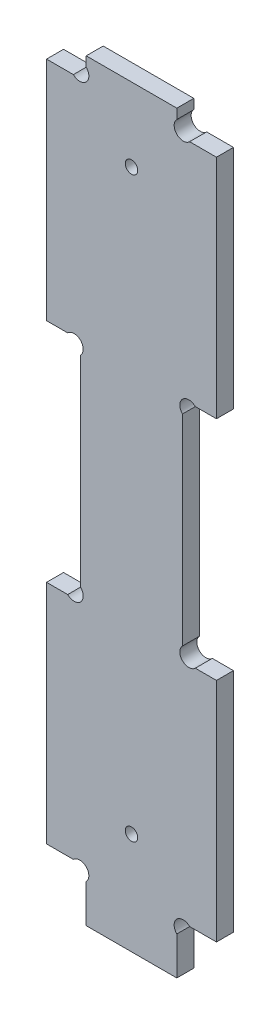
from build123d import *

# Parameters (mm, degrees)
EXTRUSION1_DEPTH        = 3
ESQUISSE2_R             = 1.1
ENL_V_MAT_EXTRU_1_DEPTH = 4


with BuildPart() as part:
    # Esquisse1 → Extrusion1 (new body)
    with BuildSketch(Plane.XY):
        with BuildLine():
            Line((25.2627417, 9), (30, 9))
            Line((30, 9), (30, 49))
            Line((30, 49), (26.2627417, 49))
            ThreePointArc((26.2627417, 49), (24, 49), (24, 51.2627417))
            Line((24, 51.2627417), (24, 86.7372583))
            ThreePointArc((24, 86.7372583), (24, 89), (26.2627417, 89))
            Line((26.2627417, 89), (30, 89))
            Line((30, 89), (30, 129))
            Line((30, 129), (25.2627417, 129))
            ThreePointArc((25.2627417, 129), (23, 129), (23, 131.2627417))
            Line((23, 131.2627417), (23, 133))
            Line((23, 133), (7, 133))
            Line((7, 133), (7, 131.2627417))
            ThreePointArc((7, 131.2627417), (7, 129), (4.7372583, 129))
            Line((4.7372583, 129), (0, 129))
            Line((0, 129), (0, 89))
            Line((0, 89), (3.7372583, 89))
            ThreePointArc((3.7372583, 89), (6, 89), (6, 86.7372583))
            Line((6, 86.7372583), (6, 51.2627417))
            ThreePointArc((6, 51.2627417), (6, 49), (3.7372583, 49))
            Line((3.7372583, 49), (0, 49))
            Line((0, 49), (0, 9))
            Line((0, 9), (4.7372583, 9))
            ThreePointArc((4.7372583, 9), (7, 9), (7, 6.7372583))
            Line((7, 6.7372583), (7, 0))
            Line((7, 0), (23, 0))
            Line((23, 0), (23, 6.7372583))
            ThreePointArc((23, 6.7372583), (23, 9), (25.2627417, 9))
        make_face()
    extrude(amount=EXTRUSION1_DEPTH)

    # Esquisse2 → Enlèv. mat.-Extru.1 (cut, through all)
    with BuildSketch(Plane.XY.offset(3)):
        with Locations((15, 18)):
            Circle(ESQUISSE2_R)
        with Locations((15, 120)):
            Circle(ESQUISSE2_R)
    extrude(amount=-ENL_V_MAT_EXTRU_1_DEPTH, mode=Mode.SUBTRACT)


solid = part.part
